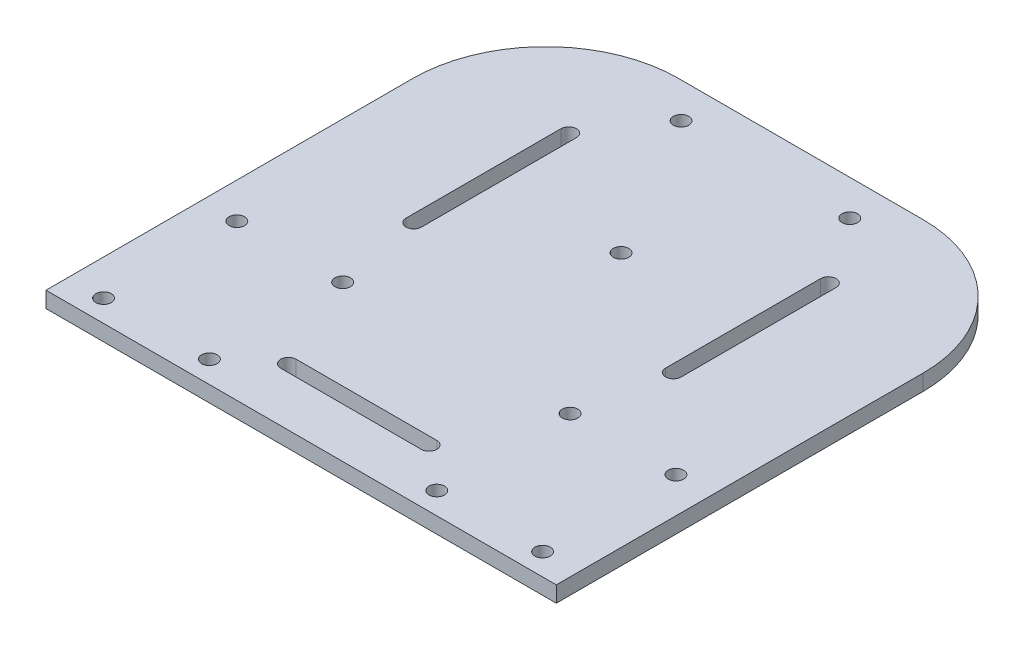
from build123d import *

# Parameters (mm, degrees)
SKETCH_6_W      = 115.2549118
SKETCH_6_H      = 112.856705034
SKETCH_6_R      = 1.75
EXTRUDE_1_DEPTH = 3.6
FILLET_2_R      = 30
FILLET_3_R      = 30


with BuildPart() as part:
    # 草图6 → 凸台-拉伸1 (new body)
    with BuildSketch(Plane(origin=(0, 0, 0), x_dir=(1, 0, 0), z_dir=(0, 1, 0))):
        with Locations((95, 83.571647483)):
            Rectangle(SKETCH_6_W, SKETCH_6_H)
        with BuildLine():
            Line((79.1225441, 41.893294966), (110.8774559, 41.893294966))
            ThreePointArc((110.8774559, 41.893294966), (112.6274559, 40.143294966), (110.8774559, 38.393294966))
            Line((110.8774559, 38.393294966), (79.1225441, 38.393294966))
            ThreePointArc((79.1225441, 38.393294966), (77.3725441, 40.143294966), (79.1225441, 41.893294966))
        make_face(mode=Mode.SUBTRACT)
        with Locations((45.4225441, 32.093294966)):
            Circle(SKETCH_6_R, mode=Mode.SUBTRACT)
        with Locations((69.3225441, 32.093294966)):
            Circle(SKETCH_6_R, mode=Mode.SUBTRACT)
        with Locations((45.4225441, 62.193294966)):
            Circle(SKETCH_6_R, mode=Mode.SUBTRACT)
        with Locations((69.3225441, 62.193294966)):
            Circle(SKETCH_6_R, mode=Mode.SUBTRACT)
        with Locations((120.6774559, 32.093294966)):
            Circle(SKETCH_6_R, mode=Mode.SUBTRACT)
        with Locations((144.5774559, 32.093294966)):
            Circle(SKETCH_6_R, mode=Mode.SUBTRACT)
        with Locations((120.6774559, 62.193294966)):
            Circle(SKETCH_6_R, mode=Mode.SUBTRACT)
        with Locations((144.5774559, 62.193294966)):
            Circle(SKETCH_6_R, mode=Mode.SUBTRACT)
        with BuildLine():
            ThreePointArc((67.429104265, 81.893294966), (65.679104265, 80.143294966), (63.929104265, 81.893294966))
            Line((63.929104265, 81.893294966), (63.929104265, 116.893294966))
            ThreePointArc((63.929104265, 116.893294966), (65.679104265, 118.643294966), (67.429104265, 116.893294966))
            Line((67.429104265, 116.893294966), (67.429104265, 81.893294966))
        make_face(mode=Mode.SUBTRACT)
        with Locations((95, 99.393294966)):
            Circle(SKETCH_6_R, mode=Mode.SUBTRACT)
        with Locations((75.95, 132)):
            Circle(SKETCH_6_R, mode=Mode.SUBTRACT)
        with BuildLine():
            Line((126.070895735, 116.893294966), (126.070895735, 81.893294966))
            ThreePointArc((126.070895735, 81.893294966), (124.320895735, 80.143294966), (122.570895735, 81.893294966))
            Line((122.570895735, 81.893294966), (122.570895735, 116.893294966))
            ThreePointArc((122.570895735, 116.893294966), (124.320895735, 118.643294966), (126.070895735, 116.893294966))
        make_face(mode=Mode.SUBTRACT)
        with Locations((114.05, 132)):
            Circle(SKETCH_6_R, mode=Mode.SUBTRACT)
    extrude(amount=EXTRUDE_1_DEPTH)

    # 圆角2
    fillet_2_edges = [part.edges().sort_by_distance(p)[0] for p in [
        (37.3725441, 1.8, -140),
    ]]
    fillet(fillet_2_edges, radius=FILLET_2_R)

    # 圆角3
    fillet_3_edges = [part.edges().sort_by_distance(p)[0] for p in [
        (152.6274559, 1.8, -140),
    ]]
    fillet(fillet_3_edges, radius=FILLET_3_R)


solid = part.part
